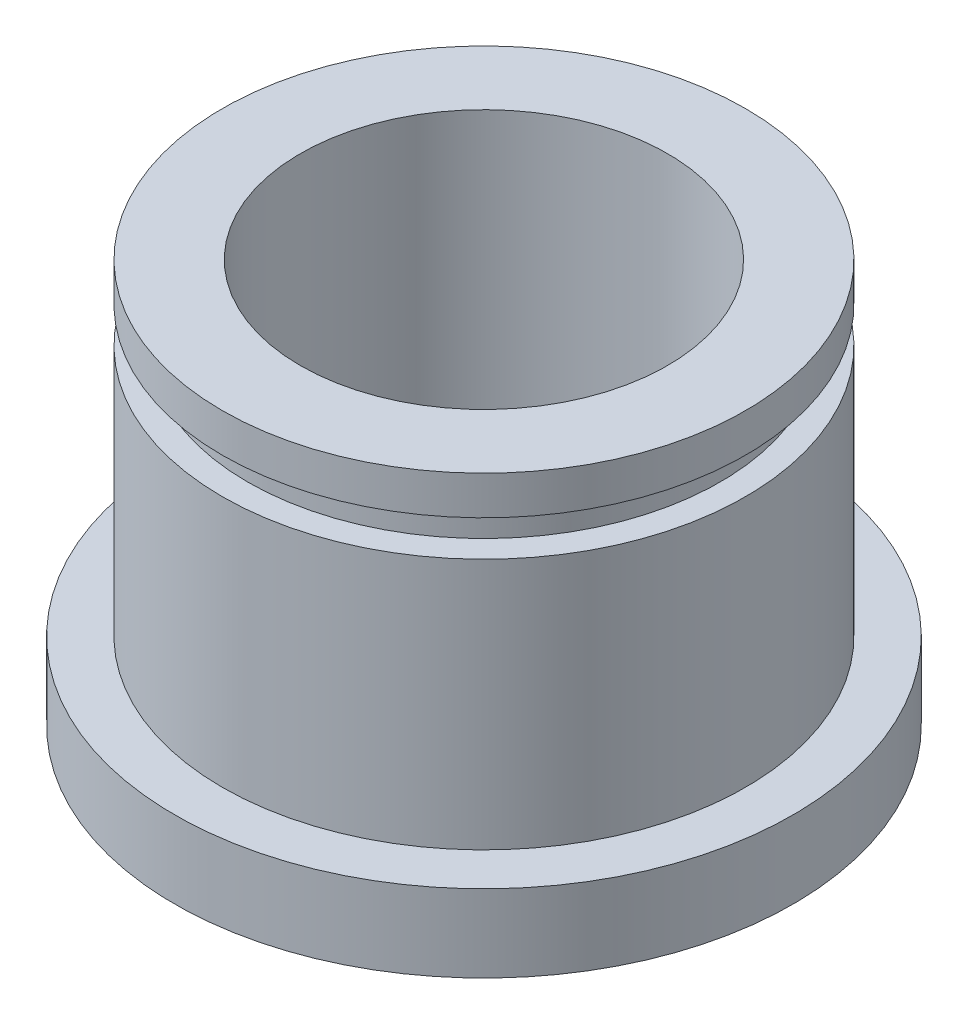
from build123d import *

# Parameters (mm, degrees)
F_19_64_0_29688_DIAMETER_HOLE1_D     = 7.540752
F_19_64_0_29688_DIAMETER_HOLE1_DEPTH = 8.382
F_19_64_0_29688_DIAMETER_HOLE1_TIP   = 2.265470457
CHAMFER1_SIZE                        = 0.79375


with BuildPart() as part:
    # Sketch1 → Revolve1 (revolve)
    with BuildSketch(Plane(origin=(0, 0, 0), x_dir=(0, 0, -1), z_dir=(1, 0, 0))):
        Polygon((0, -4.143375), (-6.35, -4.143375), (-6.35, -2.555875), (-5.3721, -2.555875), (-5.3721, 2.613025), (-4.8514, 2.613025), (-4.8514, 3.349625), (-5.3721, 3.349625), (-5.3721, 4.143375), (0, 4.143375), align=None)
    revolve(axis=Axis((0, 0, 0), (0, 1, 0)))

    # 19/64 (0.29688) Diameter Hole1
    with Locations(Plane(origin=(0, 4.143375, 0), x_dir=(1, 0, 0), z_dir=(0, 1, 0))):
        with Locations((0, 0)):
            Hole(F_19_64_0_29688_DIAMETER_HOLE1_D / 2, depth=F_19_64_0_29688_DIAMETER_HOLE1_DEPTH)
            with Locations((0, 0, -(F_19_64_0_29688_DIAMETER_HOLE1_DEPTH + F_19_64_0_29688_DIAMETER_HOLE1_TIP / 2))):  # 118° drill point
                Cone(0, F_19_64_0_29688_DIAMETER_HOLE1_D / 2, F_19_64_0_29688_DIAMETER_HOLE1_TIP, mode=Mode.SUBTRACT)

    # Chamfer1
    chamfer1_edges = [part.edges().sort_by_distance(p)[0] for p in [
        (3.770376, -4.143375, 0),
    ]]
    chamfer(chamfer1_edges, length=CHAMFER1_SIZE)


solid = part.part
